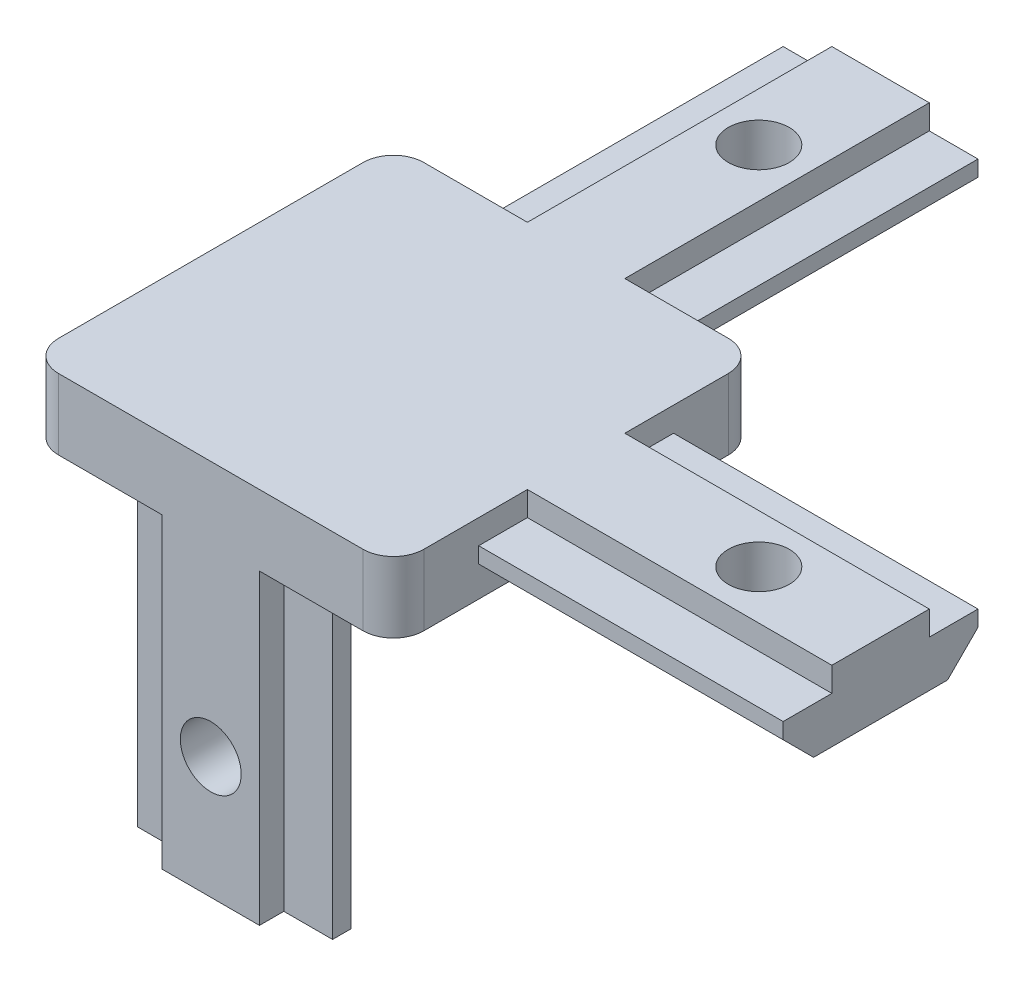
from build123d import *

# Parameters (mm, degrees)
SKETCH_1_W               = 30
SKETCH_1_H               = 30
EXTRUDE_1_DEPTH          = 5.8
EXTRUDE_2_DEPTH          = 25.2
SKETCH_3_W               = 18
SKETCH_3_H               = 18
CUT_EXTRUDE_1_DEPTH      = 1
EXTRUDE_4_DEPTH          = 25
PATTERN_CIRCULAR_1_COUNT = 2
PATTERN_CIRCULAR_1_ANGLE = 90
HOLE_WIZARD_M6_1_D       = 5
HOLE_WIZARD_M6_2_D       = 5
HOLE_WIZARD_M6_3_D       = 5
FILLET_1_R               = 2.5


with BuildPart() as part:
    # 草图1 → 凸台-拉伸1 (new body)
    with BuildSketch(Plane(origin=(0, 0, 0), x_dir=(1, 0, 0), z_dir=(0, 1, 0))):
        Rectangle(SKETCH_1_W, SKETCH_1_H)
    extrude(amount=EXTRUDE_1_DEPTH)

    # 草图2 → 凸台-拉伸2 (add)
    with BuildSketch(Plane(origin=(0, 0, 0), x_dir=(-1, 0, 0), z_dir=(0, -1, 0))):
        Polygon((4, -15), (4, -13), (8, -13), (8, -11.5), (5.5, -9), (-5.5, -9), (-8, -11.5), (-8, -13), (-4, -13), (-4, -15), align=None)
        Polygon((15, 4), (13, 4), (13, 8), (11.5, 8), (9, 5.5), (9, -5.5), (11.5, -8), (13, -8), (13, -4), (15, -4), align=None)
    extrude(amount=EXTRUDE_2_DEPTH)

    # 草图3 → 切除-拉伸1 (cut)
    with BuildSketch(Plane.XZ):
        Rectangle(SKETCH_3_W, SKETCH_3_H)
    extrude(amount=-CUT_EXTRUDE_1_DEPTH, mode=Mode.SUBTRACT)

    # 草图5 → 凸台-拉伸4 (add)
    with BuildSketch(Plane(origin=(0, 0, -15), x_dir=(-1, 0, 0), z_dir=(0, 0, -1))):
        Polygon((-5.5, 0), (5.5, 0), (8, 2.5), (8, 3.8), (4, 3.8), (4, 5.8), (-4, 5.8), (-4, 3.8), (-8, 3.8), (-8, 2.5), align=None)
    extrude_4 = extrude(amount=EXTRUDE_4_DEPTH)

    # 阵列(圆周)1: 凸台-拉伸4 ×2 about axis
    pattern_circular_1_axis = Axis((0, 0, 0), (0, -1, 0))
    for i in range(1, PATTERN_CIRCULAR_1_COUNT):
        add(extrude_4.rotate(pattern_circular_1_axis, i * PATTERN_CIRCULAR_1_ANGLE / (PATTERN_CIRCULAR_1_COUNT - 1)))

    # M6 螺纹孔1 (through all)
    with Locations(Plane(origin=(0, 0, 0), x_dir=(-1, 0, 0), z_dir=(0, -1, 0))):
        with Locations((-30, 0), (0, 30)):
            Hole(HOLE_WIZARD_M6_1_D / 2)

    # M6 螺纹孔2 (through all)
    with Locations(Plane.ZY.offset(15)):
        with Locations((0, -15.2)):
            Hole(HOLE_WIZARD_M6_2_D / 2)

    # M6 螺纹孔3 (through all)
    with Locations(Plane.XY.offset(15)):
        with Locations((0, -15.2)):
            Hole(HOLE_WIZARD_M6_3_D / 2)

    # 圆角1
    fillet_1_edges = [part.edges().sort_by_distance(p)[0] for p in [
        (15, 2.9, 15),
        (-15, 2.9, 15),
        (-15, 2.9, -15),
        (15, 2.9, -15),
    ]]
    fillet(fillet_1_edges, radius=FILLET_1_R)


solid = part.part
